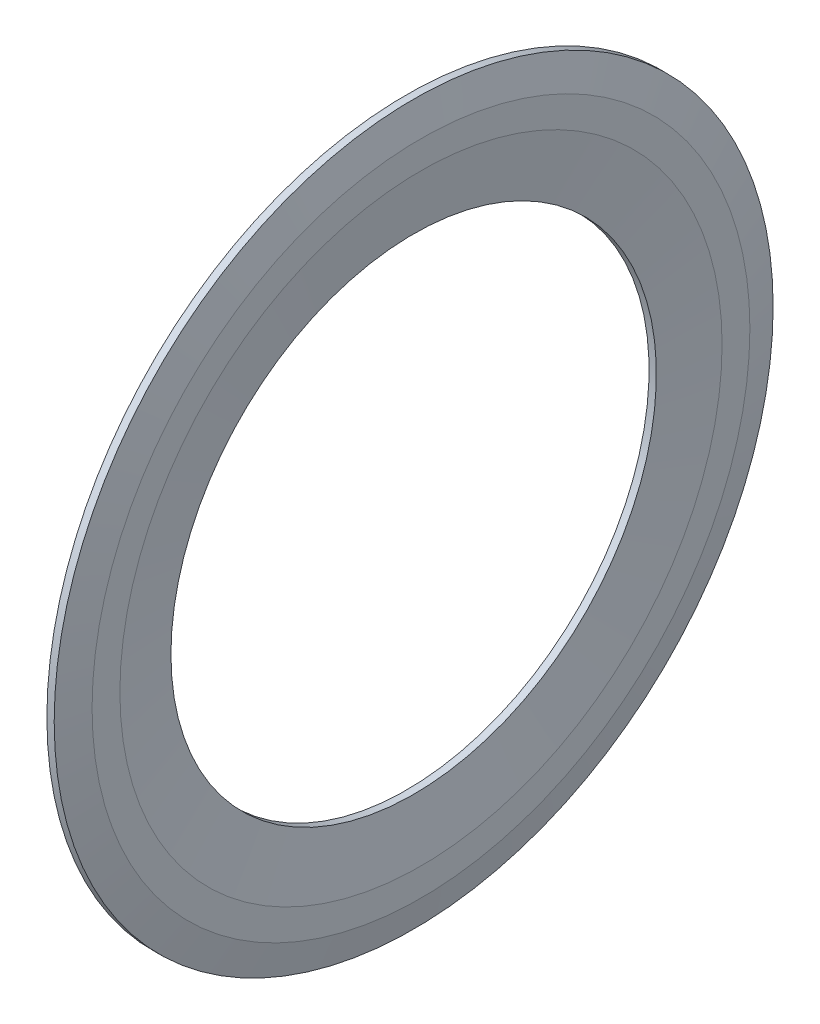
from build123d import *


with BuildPart() as part:
    # Sketch1 → Revolve1 (revolve)
    with BuildSketch(Plane.XY):
        Polygon((0.357452, 5.85), (0.417027, 5.375), (0.357452, 4.9), (0.357452, 3.95), (0.476602, 3.95), (0.595752, 4.9), (0.595752, 5.352584122), (0.476602, 5.85), align=None)
    revolve(axis=Axis((0.476602, 0, 0), (-1, 0, 0)))


solid = part.part
